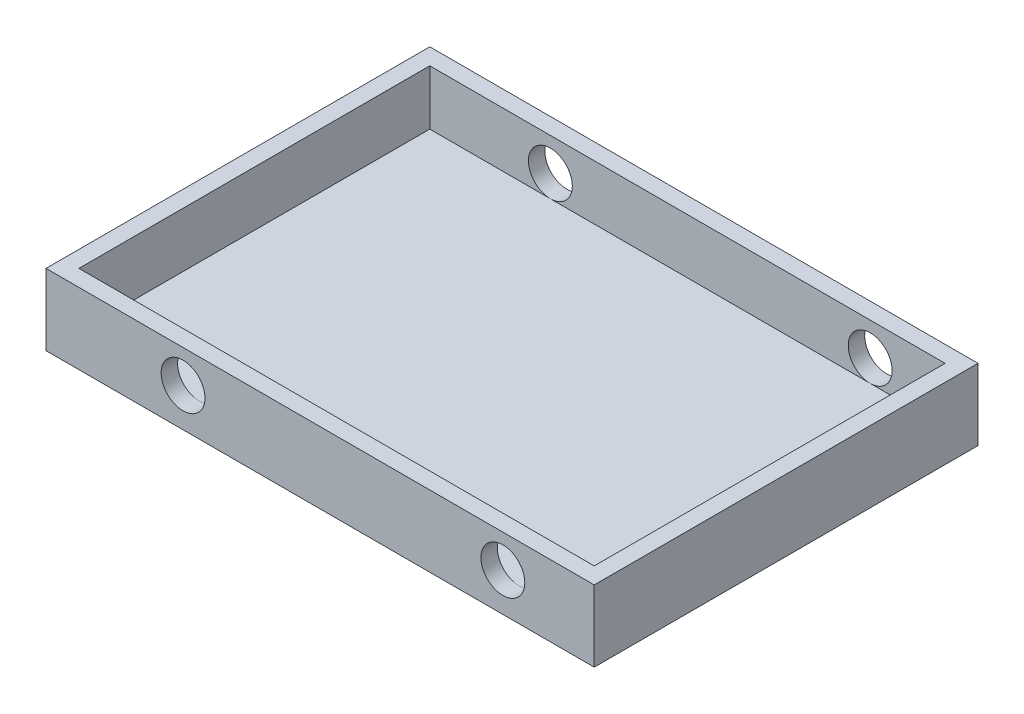
from build123d import *

# Parameters (mm, degrees)
CROQUIS1_W              = 500
CROQUIS1_H              = 350
SALIENTE_EXTRUIR1_DEPTH = 15
CROQUIS2_W              = 500
CROQUIS2_H              = 350
CROQUIS2_W_2            = 470
CROQUIS2_H_2            = 320
SALIENTE_EXTRUIR2_DEPTH = 50
CROQUIS3_R              = 20
CORTAR_EXTRUIR1_DEPTH   = 351


with BuildPart() as part:
    # Croquis1 → Saliente-Extruir1 (new body)
    with BuildSketch(Plane(origin=(0, 0, 0), x_dir=(1, 0, 0), z_dir=(0, 1, 0))):
        Rectangle(CROQUIS1_W, CROQUIS1_H)
    extrude(amount=SALIENTE_EXTRUIR1_DEPTH)

    # Croquis2 → Saliente-Extruir2 (add)
    with BuildSketch(Plane(origin=(0, 15, 0), x_dir=(1, 0, 0), z_dir=(0, 1, 0))):
        Rectangle(CROQUIS2_W, CROQUIS2_H)
        Rectangle(CROQUIS2_W_2, CROQUIS2_H_2, mode=Mode.SUBTRACT)
    extrude(amount=SALIENTE_EXTRUIR2_DEPTH)

    # Croquis3 → Cortar-Extruir1 (cut, through all)
    with BuildSketch(Plane.XY.offset(175)):
        with Locations((-125, 35)):
            Circle(CROQUIS3_R)
        with Locations((166.666666667, 35)):
            Circle(CROQUIS3_R)
    extrude(amount=-CORTAR_EXTRUIR1_DEPTH, mode=Mode.SUBTRACT)


solid = part.part
